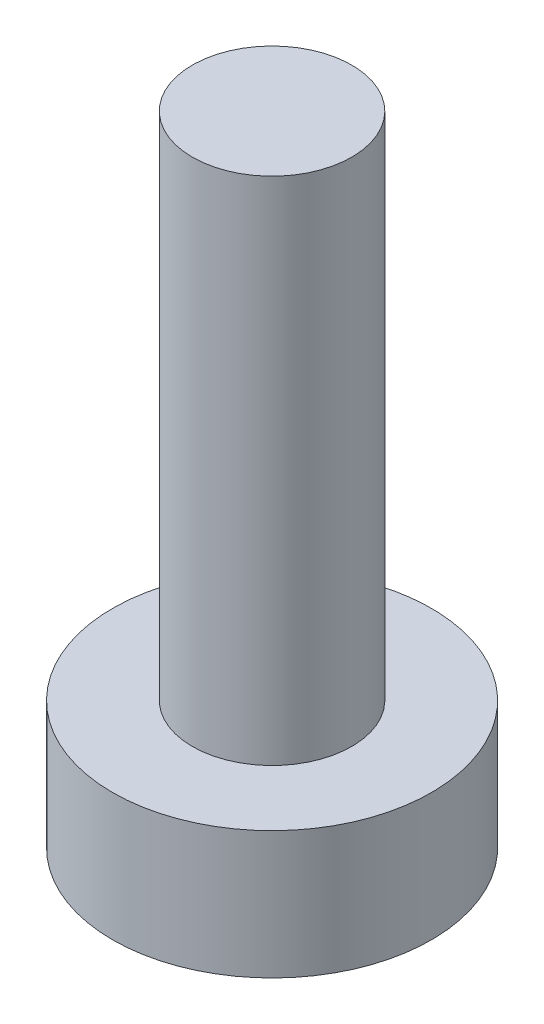
from build123d import *

# Parameters (mm, degrees)
SKETCH1_R           = 2.5
BOSS_EXTRUDE1_DEPTH = 2
SKETCH2_R           = 1.25
BOSS_EXTRUDE2_DEPTH = 8


with BuildPart() as part:
    # Sketch1 → Boss-Extrude1 (new body)
    with BuildSketch(Plane(origin=(0, 0, 0), x_dir=(1, 0, 0), z_dir=(0, 1, 0))):
        Circle(SKETCH1_R)
    extrude(amount=BOSS_EXTRUDE1_DEPTH)

    # Sketch2 → Boss-Extrude2 (add)
    with BuildSketch(Plane(origin=(0, 2, 0), x_dir=(1, 0, 0), z_dir=(0, 1, 0))):
        Circle(SKETCH2_R)
    extrude(amount=BOSS_EXTRUDE2_DEPTH)


solid = part.part
